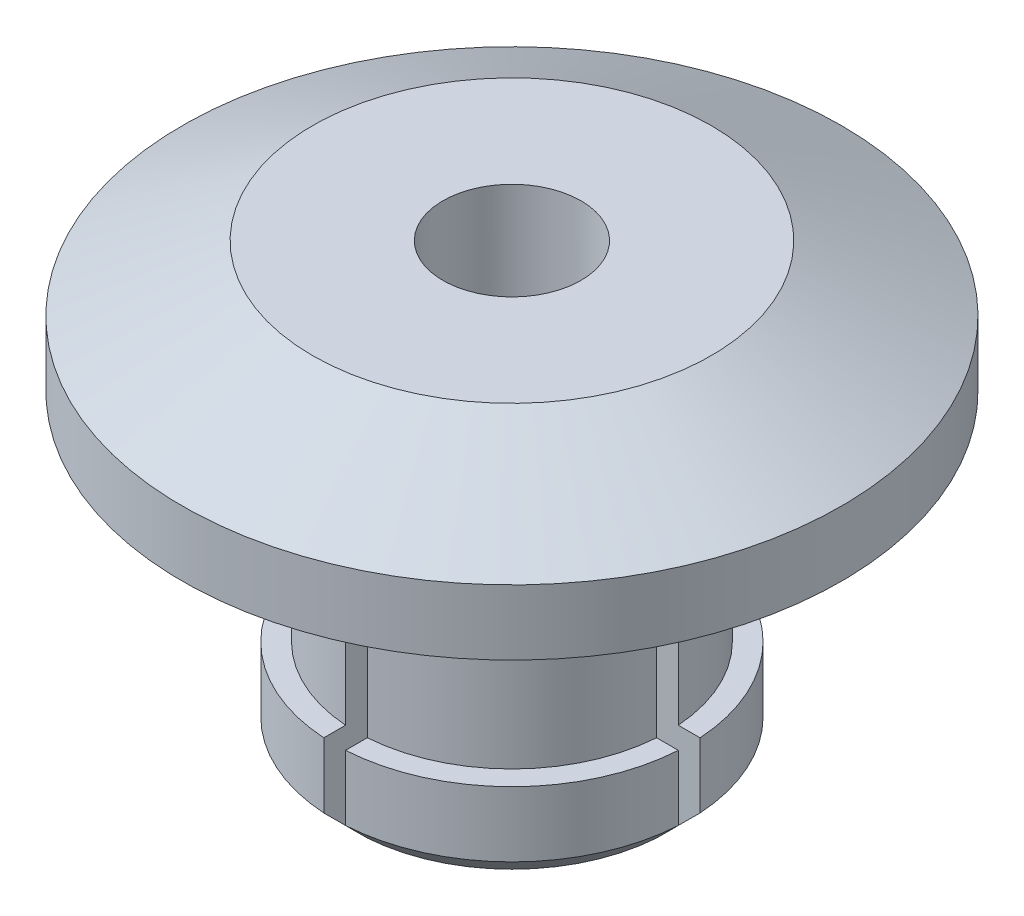
from build123d import *

# Parameters (mm, degrees)
ENL_V_MAT_EXTRU_2_DEPTH = 7


with BuildPart() as part:
    # Esquisse1 → Révolution1 (revolve)
    with BuildSketch(Plane.XY):
        Polygon((1.59, -0.870821866), (4.59, -0.870821866), (7.59, -2.370821866), (7.59, -3.870821866), (3.59, -3.870821866), (3.59, -8.870821866), (4.09, -8.870821866), (4.09, -10.370821866), (3.59, -10.870821866), (1.59, -10.870821866), (1.09, -10.370821866), (1.59, -9.870821866), (1.09, -9.370821866), (1.59, -8.870821866), (1.09, -8.370821866), (1.59, -7.870821866), align=None)
    revolve(axis=Axis((0, 0, 0), (0, 1, 0)))

    # Esquisse4 → Enlèv. mat.-Extru.2 (cut)
    with BuildSketch(Plane.XZ.offset(10.870821866)):
        Polygon((-0.25, 0.25), (-6.93889881, 0.25), (-6.93889881, -0.25), (-0.25, -0.25), (-0.25, -5.58524478), (0.25, -5.58524478), (0.25, -0.25), (11.352493463, -0.25), (11.352493463, 0.25), (0.25, 0.25), (0.25, 5.858250635), (-0.25, 5.858250635), align=None)
    extrude(amount=-ENL_V_MAT_EXTRU_2_DEPTH, mode=Mode.SUBTRACT)


solid = part.part
